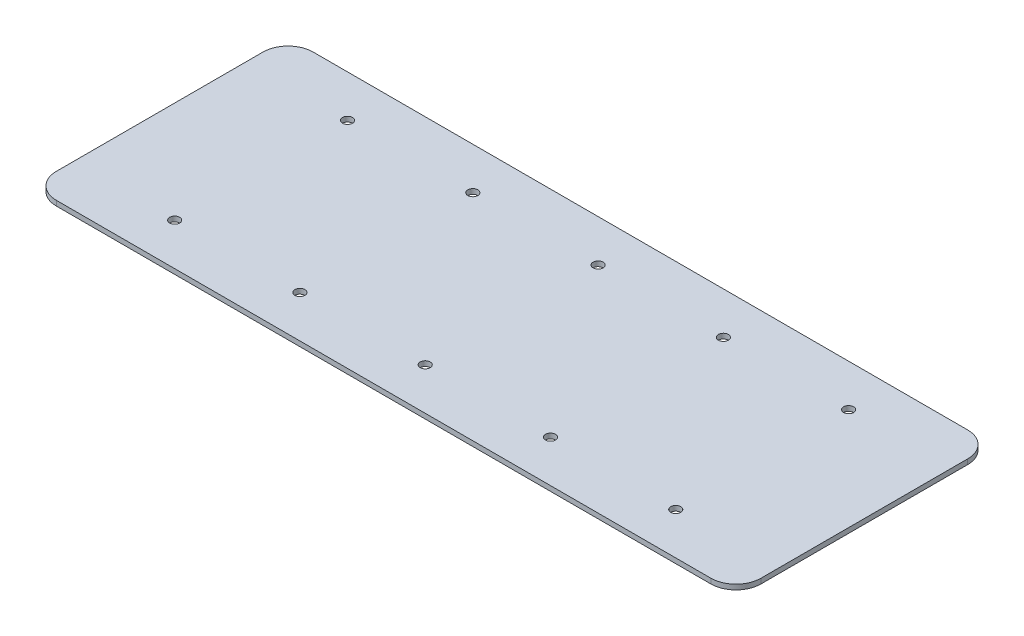
from build123d import *

# Parameters (mm, degrees)
SKETCH1_W               = 225
SKETCH1_H               = 82
BOSS_EXTRUDE1_DEPTH     = 1.6
FILLET1_R               = 8
SKETCH2_R               = 1.6
CUT_EXTRUDE1_DEPTH      = 1
CUT_EXTRUDE1_DEPTH_BACK = 2.6


with BuildPart() as part:
    # Sketch1 → Boss-Extrude1 (new body)
    with BuildSketch(Plane(origin=(0, 0, 0), x_dir=(1, 0, 0), z_dir=(0, 1, 0))):
        Rectangle(SKETCH1_W, SKETCH1_H)
    extrude(amount=BOSS_EXTRUDE1_DEPTH)

    # Fillet1
    fillet1_edges = [part.edges().sort_by_distance(p)[0] for p in [
        (112.5, 0.8, 41),
        (-112.5, 0.8, 41),
        (-112.5, 0.8, -41),
        (112.5, 0.8, -41),
    ]]
    fillet(fillet1_edges, radius=FILLET1_R)

    # Sketch2 → Cut-Extrude1 (cut, two sides)
    with BuildSketch(Plane(origin=(0, 1.6, 0), x_dir=(1, 0, 0), z_dir=(0, 1, 0))) as cut_extrude1_sk:
        with Locations((-80.11, 27.6)):
            Circle(SKETCH2_R)
        with Locations((-80.11, -27.6)):
            Circle(SKETCH2_R)
        with Locations((-40.11, 27.6)):
            Circle(SKETCH2_R)
        with Locations((-0.11, 27.6)):
            Circle(SKETCH2_R)
        with Locations((39.89, 27.6)):
            Circle(SKETCH2_R)
        with Locations((-40.11, -27.6)):
            Circle(SKETCH2_R)
        with Locations((-0.11, -27.6)):
            Circle(SKETCH2_R)
        with Locations((39.89, -27.6)):
            Circle(SKETCH2_R)
        with Locations((79.89, -27.6)):
            Circle(SKETCH2_R)
        with Locations((79.89, 27.6)):
            Circle(SKETCH2_R)
    extrude(amount=CUT_EXTRUDE1_DEPTH, mode=Mode.SUBTRACT)
    extrude(cut_extrude1_sk.sketch, amount=-CUT_EXTRUDE1_DEPTH_BACK, mode=Mode.SUBTRACT)


solid = part.part
